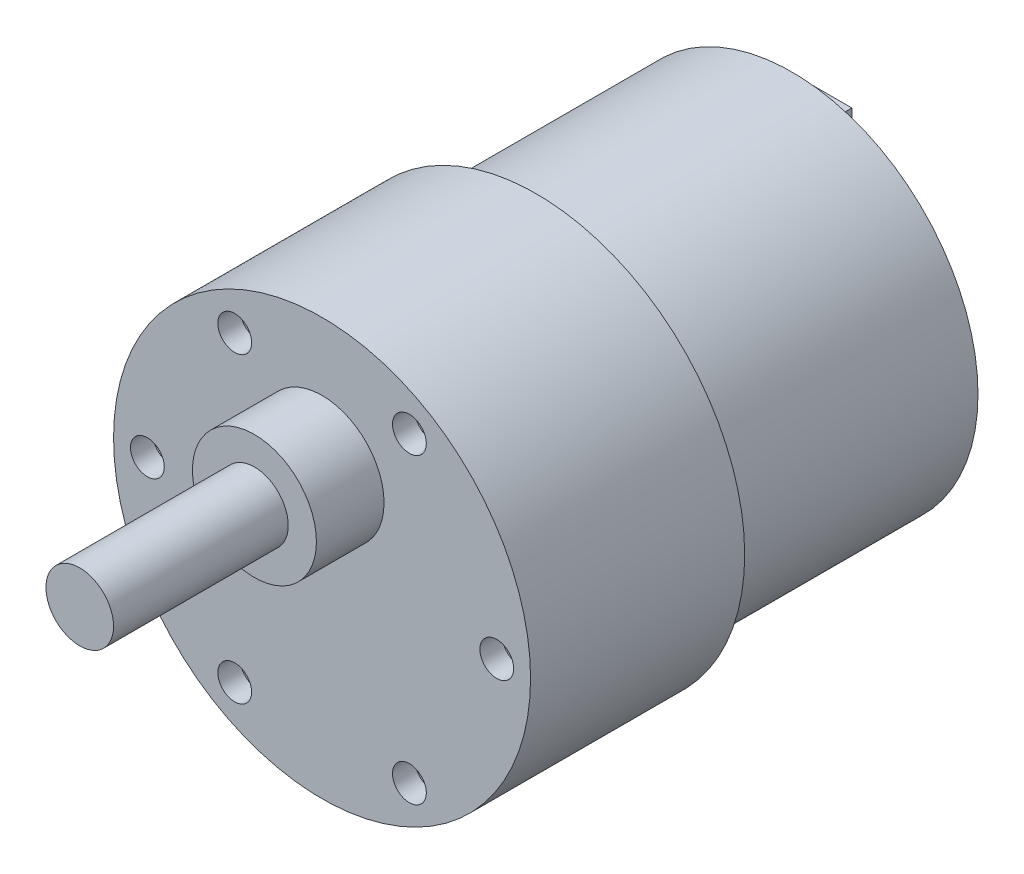
from build123d import *

# Parameters (mm, degrees)
SKETCH_1_R          = 16.5
EXTRUDE_1_DEPTH     = 22.7
SKETCH_2_R          = 18.5
EXTRUDE_2_DEPTH     = 19
SKETCH_3_R          = 1.5
CUT_EXTRUDE_1_DEPTH = 2
SKETCH_4_R          = 5.5
EXTRUDE_3_DEPTH     = 6
SKETCH_5_R          = 3
EXTRUDE_4_DEPTH     = 15.5
SKETCH_6_R          = 5
EXTRUDE_5_DEPTH     = 2.8
SKETCH_7_W          = 3.619294394
SKETCH_7_H          = 1.78180647
EXTRUDE_6_DEPTH     = 3.5


with BuildPart() as part:
    # 草图1 → 凸台-拉伸1 (new body)
    with BuildSketch(Plane.XY):
        Circle(SKETCH_1_R)
    extrude(amount=EXTRUDE_1_DEPTH)

    # 草图2 → 凸台-拉伸2 (add)
    with BuildSketch(Plane.XY.offset(22.7)):
        Circle(SKETCH_2_R)
    extrude(amount=EXTRUDE_2_DEPTH)

    # 草图3 → 切除-拉伸1 (cut)
    with BuildSketch(Plane.XY.offset(41.7)):
        with Locations((15.5, 0)):
            Circle(SKETCH_3_R)
        with Locations((7.75, -13.423393759)):
            Circle(SKETCH_3_R)
        with Locations((-7.75, -13.423393759)):
            Circle(SKETCH_3_R)
        with Locations((-15.5, 0)):
            Circle(SKETCH_3_R)
        with Locations((-7.75, 13.423393759)):
            Circle(SKETCH_3_R)
        with Locations((7.75, 13.423393759)):
            Circle(SKETCH_3_R)
    extrude(amount=-CUT_EXTRUDE_1_DEPTH, mode=Mode.SUBTRACT)

    # 草图4 → 凸台-拉伸3 (add)
    with BuildSketch(Plane.XY.offset(41.7)):
        with Locations((0, 7)):
            Circle(SKETCH_4_R)
    extrude(amount=EXTRUDE_3_DEPTH)

    # 草图5 → 凸台-拉伸4 (add)
    with BuildSketch(Plane.XY.offset(47.7)):
        with Locations((0, 7)):
            Circle(SKETCH_5_R)
    extrude(amount=EXTRUDE_4_DEPTH)

    # 草图6 → 凸台-拉伸5 (add)
    with BuildSketch(Plane(origin=(0, 0, 0), x_dir=(-1, 0, 0), z_dir=(0, 0, -1))):
        Circle(SKETCH_6_R)
    extrude(amount=EXTRUDE_5_DEPTH)

    # 草图7 → 凸台-拉伸6 (add)
    with BuildSketch(Plane(origin=(0, 0, 0), x_dir=(-1, 0, 0), z_dir=(0, 0, -1))):
        with Locations((0, 11.99935295)):
            Rectangle(SKETCH_7_W, SKETCH_7_H)
        with Locations((0, -11.99935295)):
            Rectangle(SKETCH_7_W, SKETCH_7_H)
    extrude(amount=EXTRUDE_6_DEPTH)


solid = part.part
